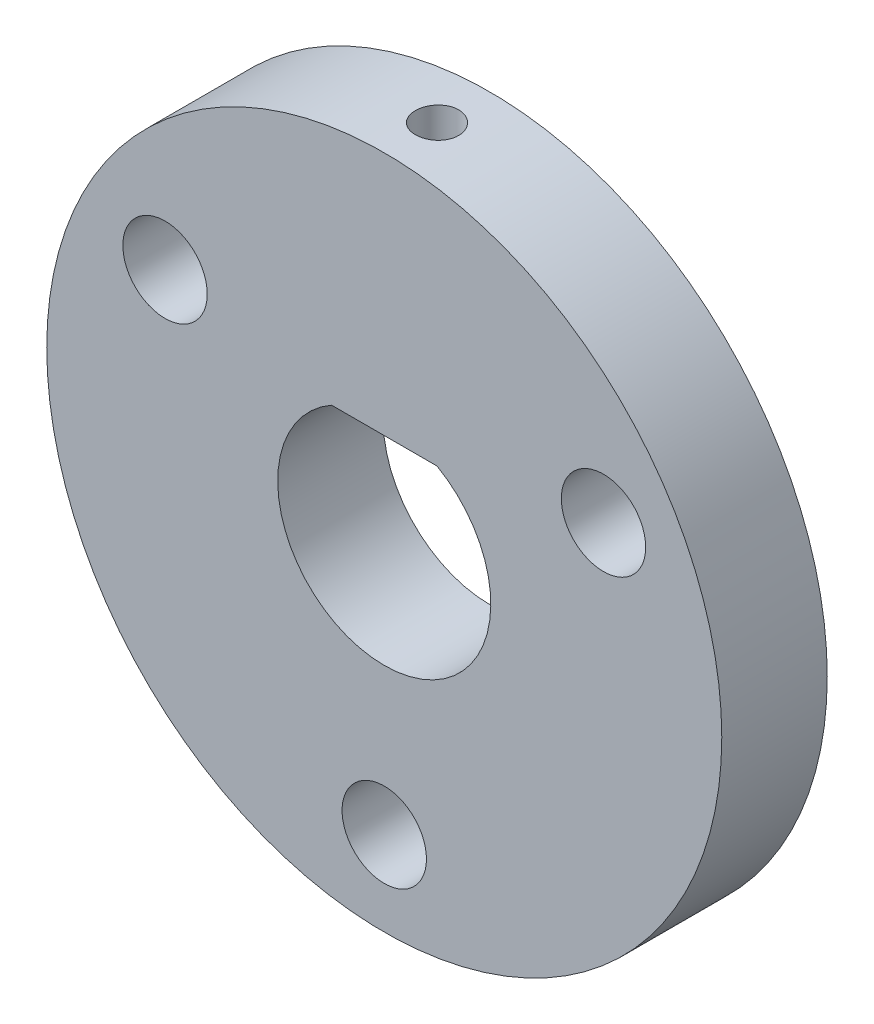
from build123d import *

# Parameters (mm, degrees)
SKETCH1_R            = 16
BOSS_EXTRUDE1_DEPTH  = 2.5
M4_CLEARANCE_HOLE2_D = 4
CIRPATTERN1_COUNT    = 3
SKETCH7_W            = 1.025
SKETCH7_H            = 11.612232914


with BuildPart() as part:
    # Sketch1 → Boss-Extrude1 (new body, symmetric)
    with BuildSketch(Plane.XY):
        Circle(SKETCH1_R)
        with BuildLine():
            Line((-2.5, 4.387767086), (2.5, 4.387767086))
            ThreePointArc((2.5, 4.387767086), (0, -5.05), (-2.5, 4.387767086))
        make_face(mode=Mode.SUBTRACT)
    extrude(amount=BOSS_EXTRUDE1_DEPTH, both=True)

    # M4 Clearance Hole2 (through all)
    with Locations(Plane.XY.offset(2.5)):
        with Locations((0, -12)):
            m4_clearance_hole2 = Hole(M4_CLEARANCE_HOLE2_D / 2)

    # CirPattern1: M4 Clearance Hole2 ×3 about axis
    cirpattern1_axis = Axis((0, 0, 0), (0, 0, 1))
    for i in range(1, CIRPATTERN1_COUNT):
        add(m4_clearance_hole2.rotate(cirpattern1_axis, i * 360 / CIRPATTERN1_COUNT), mode=Mode.SUBTRACT)

    # Sketch7 → M2.5x0.45 Tapped Hole1 (revolve, cut)
    with BuildSketch(Plane(origin=(0, 4.387767086, 0), x_dir=(0, 0, -1), z_dir=(1, 0, 0))):
        with Locations((0.5125, 5.806116457)):
            Rectangle(SKETCH7_W, SKETCH7_H)
    revolve(axis=Axis((0, -1.962232914, 0), (0, 1, 0)), mode=Mode.SUBTRACT)


solid = part.part
